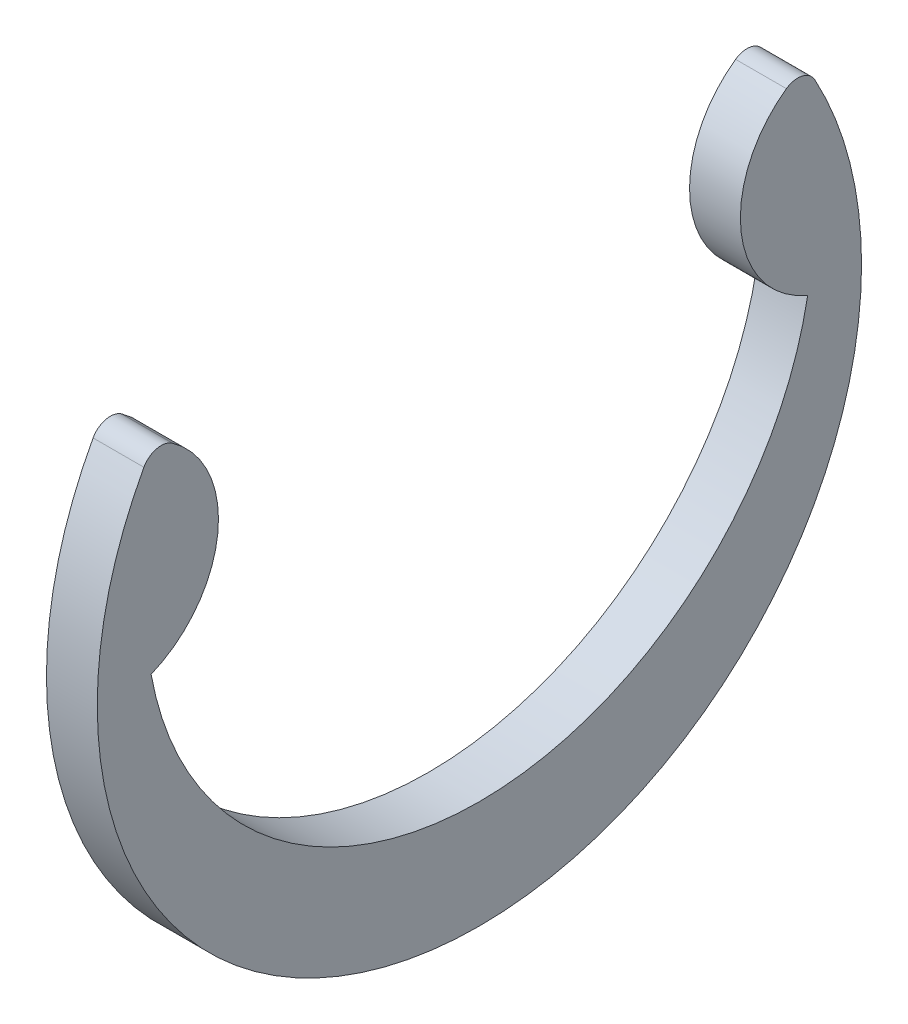
from build123d import *

# Parameters (mm, degrees)
EXTRUDE1_DEPTH = 0.3175


with BuildPart() as part:
    # Sketch1 → Extrude1 (new body, symmetric)
    with BuildSketch(Plane(origin=(0, 0, 0), x_dir=(0, 0, -1), z_dir=(1, 0, 0))):
        with BuildLine():
            ThreePointArc((-4.1021, 0), (0, -3.429), (4.1021, 0))
            ThreePointArc((4.1021, 0), (3.269449594, 1.105861316), (3.836428871, 2.368703526))
            ThreePointArc((3.836428871, 2.368703526), (4.032995284, 2.407207291), (4.192462169, 2.286))
            ThreePointArc((4.192462169, 2.286), (0, -4.7752), (-4.192462169, 2.286))
            ThreePointArc((-4.192462169, 2.286), (-4.032995284, 2.407207291), (-3.836428871, 2.368703526))
            ThreePointArc((-3.836428871, 2.368703526), (-3.269449594, 1.105861316), (-4.1021, 0))
        make_face()
    extrude(amount=EXTRUDE1_DEPTH, both=True)


solid = part.part
